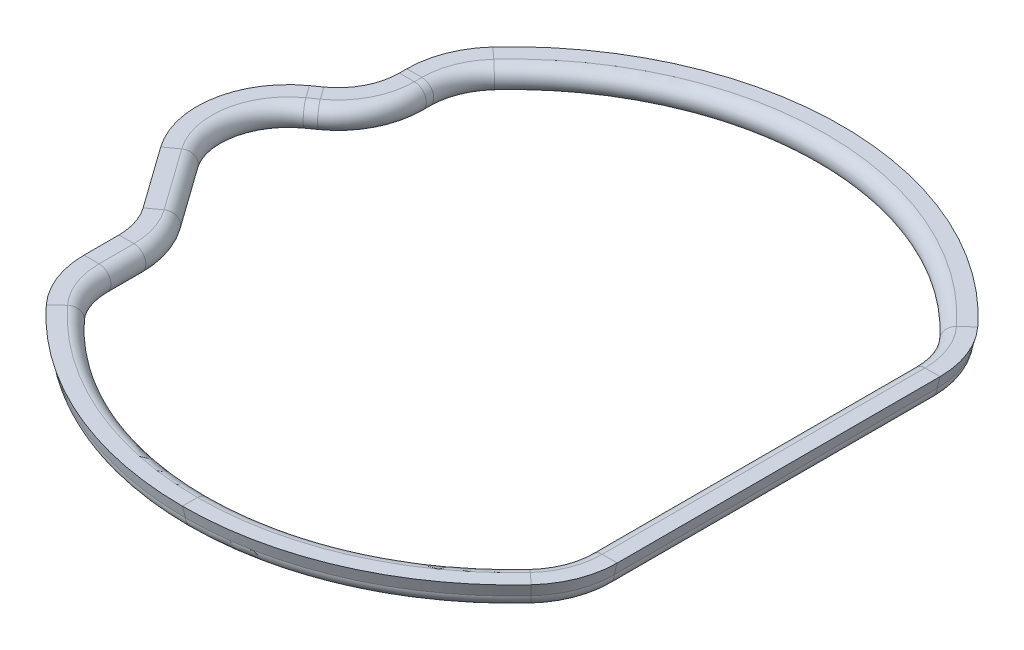
from build123d import *


with BuildPart() as part:
    # Austragung1: sweep along a path in Skizze1
    with BuildLine(Plane(origin=(0, 0, 0), x_dir=(1, 0, 0), z_dir=(0, 1, 0))) as austragung1_path:
        Line((-69.654529262, -21.528063223), (-81.174051866, -5.393202266))
        ThreePointArc((-81.174051866, -5.393202266), (-84.623968891, 9.520303277), (-76.517987713, 22.5052039))
        Line((-76.517987713, 22.5052039), (-74.310593415, 24.081178344))
        ThreePointArc((-74.310593415, 24.081178344), (-68.149421773, 31.204819131), (-65.931764421, 40.358413503))
        Line((-65.931764421, 40.358413503), (-65.931764421, 42.300814045))
        ThreePointArc((-65.931764421, 42.300814045), (-64.562830296, 49.572910331), (-60.643425983, 55.849504539))
        ThreePointArc((-60.643425983, 55.849504539), (0, 82.442660512), (60.643425983, 55.849504539))
        ThreePointArc((60.643425983, 55.849504539), (64.562830296, 49.572910331), (65.931764421, 42.300814045))
        Line((65.931764421, 42.300814045), (65.931764421, -42.300814045))
        ThreePointArc((65.931764421, -42.300814045), (64.562830296, -49.572910331), (60.643425983, -55.849504539))
        ThreePointArc((60.643425983, -55.849504539), (0, -82.442660512), (-60.643425983, -55.849504539))
        ThreePointArc((-60.643425983, -55.849504539), (-64.562830296, -49.572910331), (-65.931764421, -42.300814045))
        Line((-65.931764421, -42.300814045), (-65.931764421, -33.149234229))
        ThreePointArc((-65.931764421, -33.149234229), (-66.885180696, -27.04778781), (-69.654529262, -21.528063223))
    # Skizze2 → Austragung1 (sweep)
    with BuildSketch(Plane(origin=(0, 0, 0), x_dir=(0, 0, -1), z_dir=(1, 0, 0))):
        with BuildLine():
            Line((-82.442660512, 3.114282512), (-86.384630622, 3.114282512))
            Line((-86.384630622, 3.114282512), (-85.556943024, 0))
            ThreePointArc((-85.556943024, 0), (-80.240530229, -2.202130283), (-82.442660512, 3.114282512))
        make_face()
    sweep(path=austragung1_path.line)


solid = part.part
